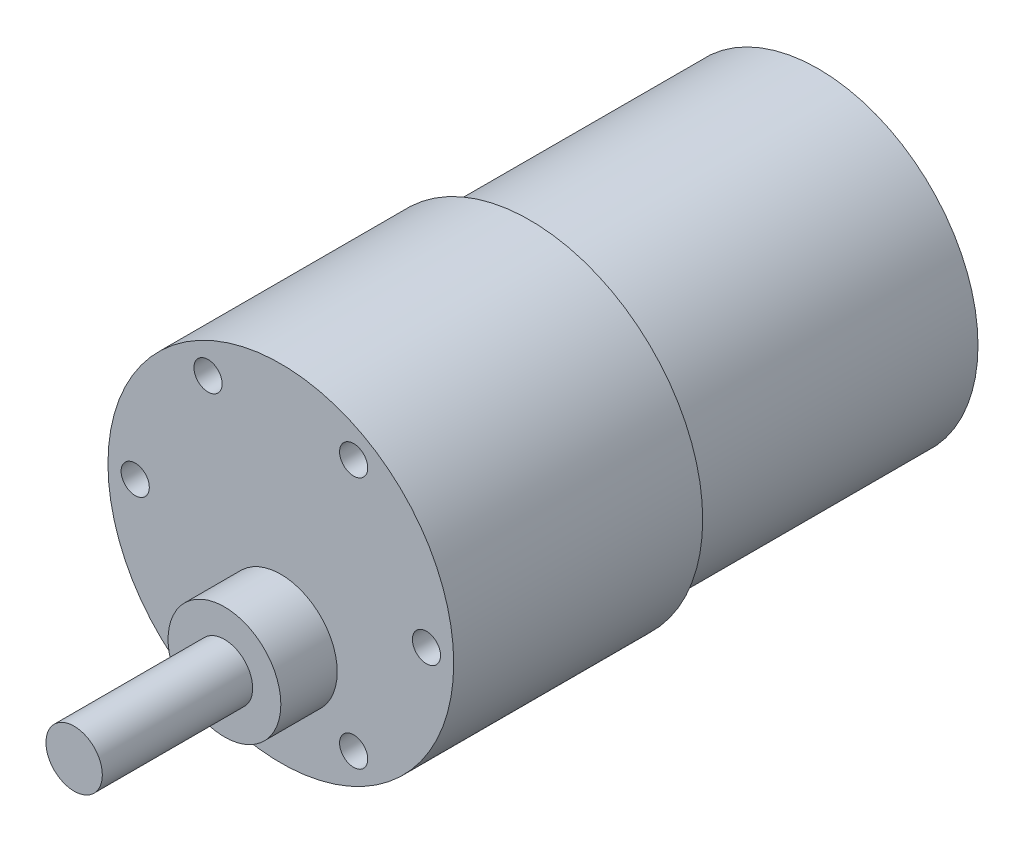
from build123d import *

# Parameters (mm, degrees)
CROQUIS1_R              = 18.4
SALIENTE_EXTRUIR1_DEPTH = 26.5
CROQUIS2_R              = 17
SALIENTE_EXTRUIR2_DEPTH = 30.7
CROQUIS3_R              = 1.5
CORTAR_EXTRUIR1_DEPTH   = 5
CROQUIS4_R              = 6
SALIENTE_EXTRUIR3_DEPTH = 6
CROQUIS5_R              = 3
SALIENTE_EXTRUIR4_DEPTH = 16


with BuildPart() as part:
    # Croquis1 → Saliente-Extruir1 (new body)
    with BuildSketch(Plane.XY):
        Circle(CROQUIS1_R)
    extrude(amount=SALIENTE_EXTRUIR1_DEPTH)

    # Croquis2 → Saliente-Extruir2 (add)
    with BuildSketch(Plane(origin=(0, 0, 0), x_dir=(-1, 0, 0), z_dir=(0, 0, -1))):
        Circle(CROQUIS2_R)
    extrude(amount=SALIENTE_EXTRUIR2_DEPTH)

    # Croquis3 → Cortar-Extruir1 (cut)
    with BuildSketch(Plane.XY.offset(26.5)):
        with Locations((-15.5, 0)):
            Circle(CROQUIS3_R)
        with Locations((-7.75, 13.423393759)):
            Circle(CROQUIS3_R)
        with Locations((7.75, 13.423393759)):
            Circle(CROQUIS3_R)
        with Locations((15.5, 0)):
            Circle(CROQUIS3_R)
        with Locations((7.75, -13.423393759)):
            Circle(CROQUIS3_R)
        with Locations((-7.75, -13.423393759)):
            Circle(CROQUIS3_R)
    extrude(amount=-CORTAR_EXTRUIR1_DEPTH, mode=Mode.SUBTRACT)

    # Croquis4 → Saliente-Extruir3 (add)
    with BuildSketch(Plane.XY.offset(26.5)):
        with Locations((0, -7)):
            Circle(CROQUIS4_R)
    extrude(amount=SALIENTE_EXTRUIR3_DEPTH)

    # Croquis5 → Saliente-Extruir4 (add)
    with BuildSketch(Plane.XY.offset(32.5)):
        with Locations((0, -7)):
            Circle(CROQUIS5_R)
    extrude(amount=SALIENTE_EXTRUIR4_DEPTH)


solid = part.part
